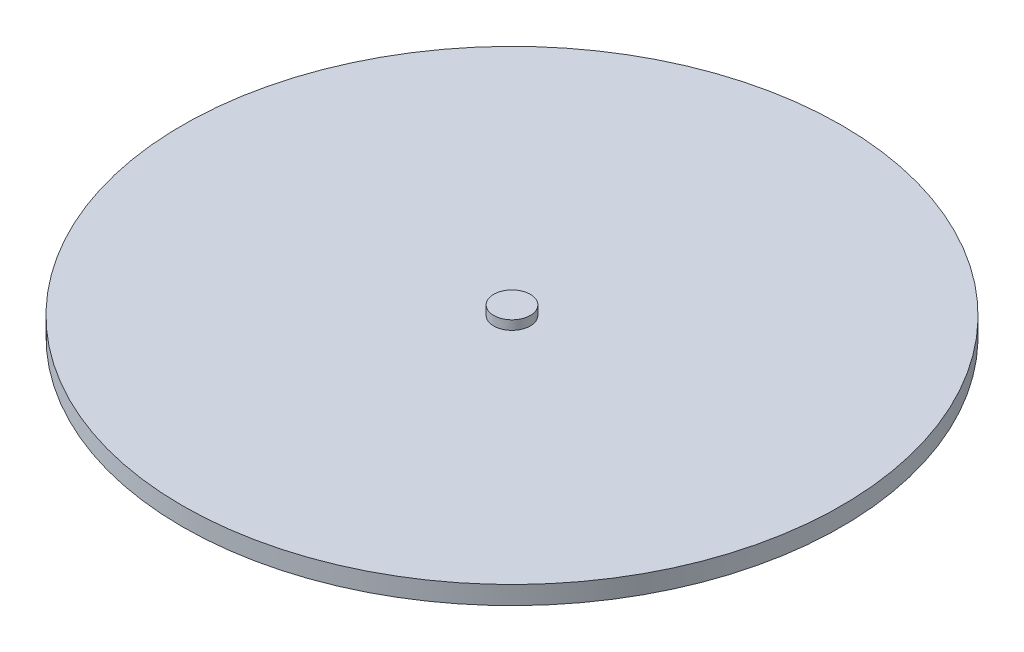
from build123d import *

# Parameters (mm, degrees)
SKETCH1_R           = 228.6
BOSS_EXTRUDE1_DEPTH = 6.35
SKETCH2_R           = 12.7
BOSS_EXTRUDE2_DEPTH = 6.35


with BuildPart() as part:
    # Sketch1 → Boss-Extrude1 (new body, symmetric)
    with BuildSketch(Plane(origin=(0, 0, 0), x_dir=(1, 0, 0), z_dir=(0, 1, 0))):
        Circle(SKETCH1_R)
    extrude(amount=BOSS_EXTRUDE1_DEPTH, both=True)

    # Sketch2 → Boss-Extrude2 (add)
    with BuildSketch(Plane(origin=(0, 6.35, 0), x_dir=(1, 0, 0), z_dir=(0, 1, 0))):
        Circle(SKETCH2_R)
    extrude(amount=BOSS_EXTRUDE2_DEPTH)


solid = part.part
